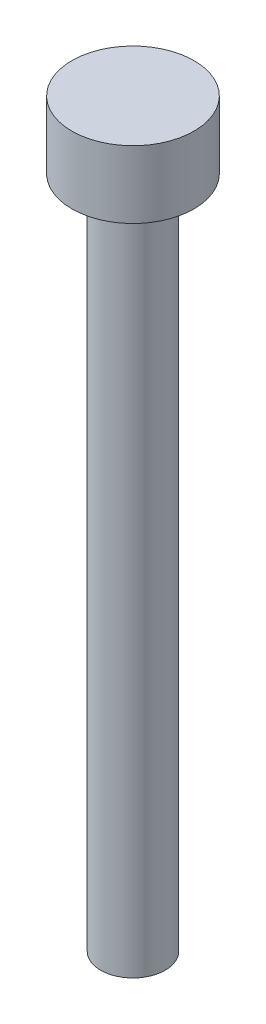
from build123d import *

# Parameters (mm, degrees)
SKETCH1_R           = 2.72
BOSS_EXTRUDE1_DEPTH = 3
SKETCH2_R           = 1.44
BOSS_EXTRUDE2_DEPTH = 30


with BuildPart() as part:
    # Sketch1 → Boss-Extrude1 (new body)
    with BuildSketch(Plane(origin=(0, 0, 0), x_dir=(1, 0, 0), z_dir=(0, 1, 0))):
        Circle(SKETCH1_R)
    extrude(amount=BOSS_EXTRUDE1_DEPTH)

    # Sketch2 → Boss-Extrude2 (add)
    with BuildSketch(Plane.XZ):
        Circle(SKETCH2_R)
    extrude(amount=BOSS_EXTRUDE2_DEPTH)


solid = part.part
